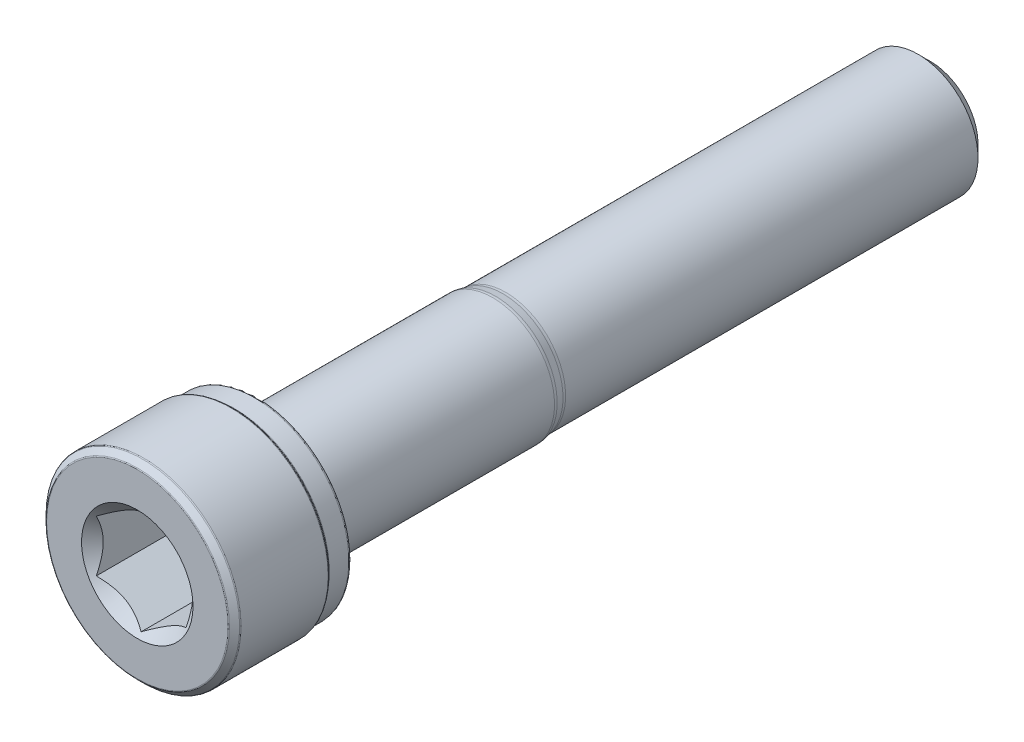
from build123d import *

# Parameters (mm, degrees)
CUT_EXTRUDE1_DEPTH = 7


with BuildPart() as part:
    # Sketch2 → Revolve1 (revolve)
    with BuildSketch(Plane(origin=(0, 0, 0), x_dir=(0, 0, -1), z_dir=(1, 0, 0)), mode=Mode.PRIVATE) as revolve1_sk:
        with BuildLine():
            Line((-26.5, 0), (-26.5, 6.058578644))
            ThreePointArc((-26.5, 6.058578644), (-26.492387953, 6.096846987), (-26.470710678, 6.129289322))
            Line((-26.470710678, 6.129289322), (-26.129289322, 6.470710678))
            ThreePointArc((-26.129289322, 6.470710678), (-26.096846987, 6.492387953), (-26.058578644, 6.5))
            Line((-26.058578644, 6.5), (-20.241421356, 6.5))
            ThreePointArc((-20.241421356, 6.5), (-20.203153013, 6.492387953), (-20.170710678, 6.470710678))
            Line((-20.170710678, 6.470710678), (-20.029289322, 6.329289322))
            ThreePointArc((-20.029289322, 6.329289322), (-19.996846987, 6.307612047), (-19.958578644, 6.3))
            Line((-19.958578644, 6.3), (-18.6625, 6.3))
            ThreePointArc((-18.6625, 6.3), (-18.547595148, 6.252404852), (-18.5, 6.1375))
            Line((-18.5, 6.1375), (-18.5, 4.535316469))
            ThreePointArc((-18.5, 4.535316469), (-18.382842712, 4.252473757), (-18.1, 4.135316469))
            Line((-18.1, 4.135316469), (-2.747523234, 4.135316469))
            ThreePointArc((-2.747523234, 4.135316469), (-2.649506093, 4.130501196), (-2.552432912, 4.11610175))
            Line((-2.552432912, 4.11610175), (-2.065348919, 4.01921472))
            ThreePointArc((-2.065348919, 4.01921472), (-1.968275737, 4.004815273), (-1.870258597, 4))
            Line((-1.870258597, 4), (25.688101184, 4))
            Line((25.688101184, 4), (26.5, 3.188101184))
            Line((26.5, 3.188101184), (26.5, 0))
            Line((26.5, 0), (-26.5, 0))
        make_face()
    revolve(revolve1_sk.sketch.rotate(Axis((0, 0, -26.5), (0, 0, 1)), 90), axis=Axis((0, 0, -26.5), (0, 0, 1)))

    # Sketch3 → Cut-Extrude1 (cut)
    with BuildSketch(Plane.XY.offset(26.5)):
        Polygon((3, -1.732050808), (3, 1.732050808), (0, 3.464101615), (-3, 1.732050808), (-3, -1.732050808), (0, -3.464101615), align=None)
    extrude(amount=-CUT_EXTRUDE1_DEPTH, mode=Mode.SUBTRACT)

    # Cut-Extrude2 cone 1 section (through the dimple's axis) → Cut-Extrude2 (revolve, cut)
    with BuildSketch(Plane(origin=(0, 0, 26.5), x_dir=(0, -1, 0), z_dir=(1, 0, 0))):
        Polygon((0, 0), (3.723909236, 0), (0, 3.723909236), align=None)
    revolve(axis=Axis((0, 0, 26.5), (0, 0, -1)), mode=Mode.SUBTRACT)


solid = part.part
